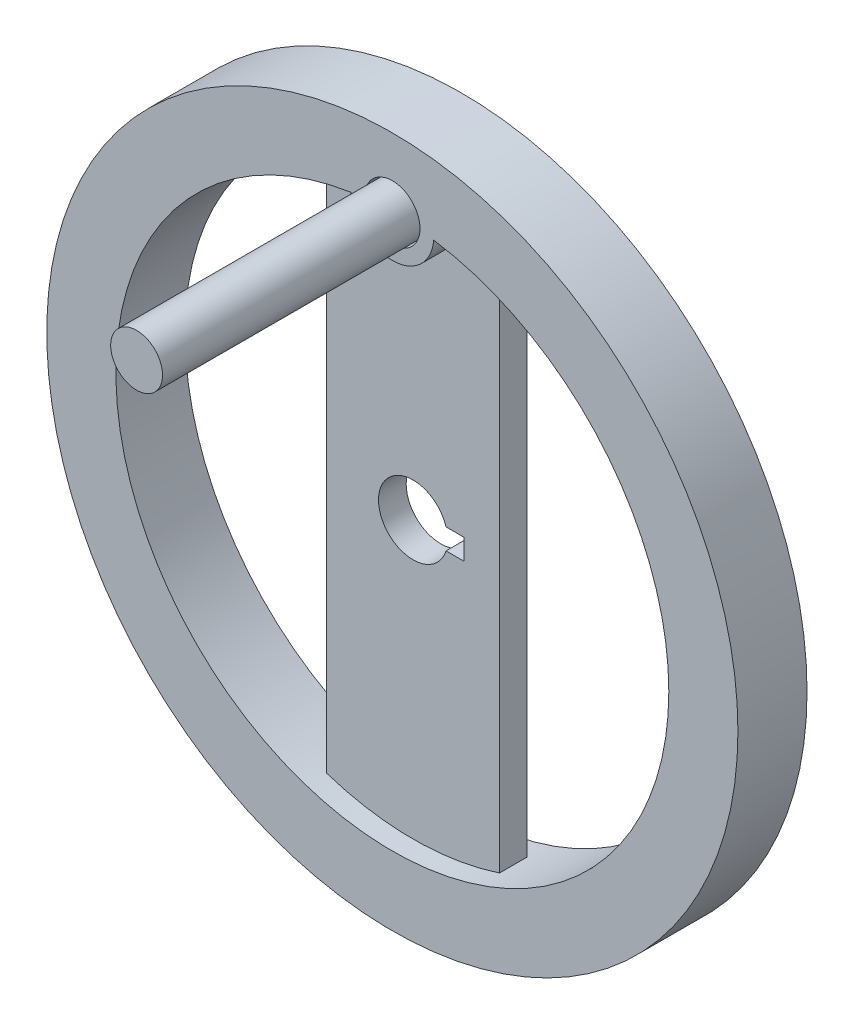
from build123d import *

# Parameters (mm, degrees)
SKETCH_1_R          = 50
EXTRUDE_1_DEPTH     = 5
SKETCH_2_R          = 40
CUT_EXTRUDE_1_DEPTH = 3
CUT_EXTRUDE_2_DEPTH = 10
SKETCH_4_R          = 6
SKETCH_4_R_2        = 4
EXTRUDE_2_DEPTH     = 3
SKETCH_5_R          = 4
CUT_EXTRUDE_3_DEPTH = 3
SKETCH_6_R          = 3.75
EXTRUDE_3_DEPTH     = 40


with BuildPart() as part:
    # 草图1 → 凸台-拉伸1 (new, symmetric)
    with BuildSketch(Plane.XY):
        Circle(SKETCH_1_R)
        with BuildLine():
            Line((4.769696007, 1.5), (7.369696007, 1.5))
            Line((7.369696007, 1.5), (7.369696007, -1.5))
            Line((7.369696007, -1.5), (4.769696007, -1.5))
            ThreePointArc((4.769696007, -1.5), (-5, 0), (4.769696007, 1.5))
        make_face(mode=Mode.SUBTRACT)
    extrude(amount=EXTRUDE_1_DEPTH, both=True)

    # 草图2 → 切除-拉伸1 (cut)
    with BuildSketch(Plane.XY.offset(5)):
        Circle(SKETCH_2_R)
    cut_extrude_1 = extrude(amount=-CUT_EXTRUDE_1_DEPTH, mode=Mode.SUBTRACT)

    # 镜向1: 切除-拉伸1 across plane
    add(cut_extrude_1.mirror(Plane.XY), mode=Mode.SUBTRACT)

    # 草图3 → 切除-拉伸2 (cut)
    with BuildSketch(Plane.XY.offset(2)):
        with BuildLine():
            Line((-12.5, 37.996710384), (-12.5, -37.996710384))
            ThreePointArc((-12.5, -37.996710384), (-40, 0), (-12.5, 37.996710384))
        make_face()
        with BuildLine():
            Line((12.5, 37.996710384), (12.5, -37.996710384))
            ThreePointArc((12.5, -37.996710384), (40, 0), (12.5, 37.996710384))
        make_face()
    extrude(amount=-CUT_EXTRUDE_2_DEPTH, mode=Mode.SUBTRACT)

    # 草图5 → 切除-拉伸3 (cut)
    with BuildSketch(Plane.XY.offset(5)):
        with Locations((0, 40)):
            Circle(SKETCH_5_R)
    extrude(amount=-CUT_EXTRUDE_3_DEPTH, mode=Mode.SUBTRACT)


with BuildPart() as body_2:
    # 草图4 → 凸台-拉伸2 (new body)
    with BuildSketch(Plane.XY.offset(2)):
        with Locations((0, 40)):
            Circle(SKETCH_4_R)
        with Locations((0, 40)):
            Circle(SKETCH_4_R_2, mode=Mode.SUBTRACT)
    extrude(amount=EXTRUDE_2_DEPTH)


    add(part.part)  # 凸台-拉伸3 merges part
    # 草图6 → 凸台-拉伸3 (add)
    with BuildSketch(Plane.XY.offset(2)):
        with Locations((0, 40)):
            Circle(SKETCH_6_R)
    extrude(amount=EXTRUDE_3_DEPTH)


solid = body_2.part
